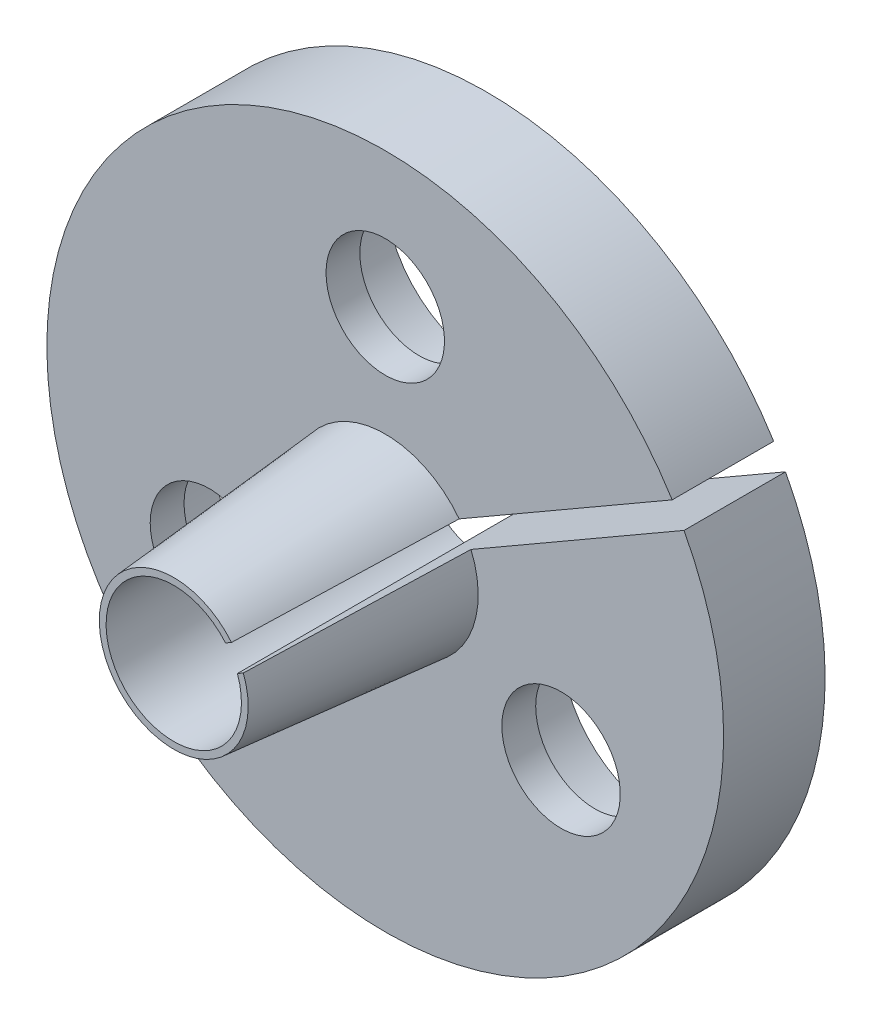
from build123d import *

# Parameters (mm, degrees)
SKETCH4_R           = 10
SKETCH4_R_2         = 2
BOSS_EXTRUDE4_DEPTH = 3
SKETCH5_R           = 1.75
CUT_EXTRUDE1_DEPTH  = 10.25
SKETCH7_R           = 3
CUT_EXTRUDE3_DEPTH  = 2
CUT_EXTRUDE2_DEPTH  = 10.25


with BuildPart() as part:
    # Sketch3 → Revolve1 (revolve)
    with BuildSketch(Plane(origin=(0, 0, 0), x_dir=(0, 0, -1), z_dir=(1, 0, 0))):
        Polygon((0, 2), (0, 2.746804147), (-6.25, 2.2), (-6.25, 2), align=None)
    revolve(axis=Axis((0, 0, 0), (0, 0, 1)))

    # Sketch4 → Boss-Extrude4 (add)
    with BuildSketch(Plane(origin=(0, 0, 0), x_dir=(-1, 0, 0), z_dir=(0, 0, -1))):
        Circle(SKETCH4_R)
        Circle(SKETCH4_R_2, mode=Mode.SUBTRACT)
    extrude(amount=BOSS_EXTRUDE4_DEPTH)

    # Sketch5 → Cut-Extrude1 (cut, through all)
    with BuildSketch(Plane(origin=(0, 0, -3), x_dir=(-1, 0, 0), z_dir=(0, 0, -1))):
        with Locations((0, 6)):
            Circle(SKETCH5_R)
        with Locations((-5.196152423, -3)):
            Circle(SKETCH5_R)
        with Locations((5.196152423, -3)):
            Circle(SKETCH5_R)
    extrude(amount=-CUT_EXTRUDE1_DEPTH, mode=Mode.SUBTRACT)

    # Sketch7 → Cut-Extrude3 (cut)
    with BuildSketch(Plane(origin=(0, 0, -3), x_dir=(-1, 0, 0), z_dir=(0, 0, -1))):
        with Locations((0, 6)):
            Circle(SKETCH7_R)
        with Locations((5.196152423, -3)):
            Circle(SKETCH7_R)
        with Locations((-5.196152423, -3)):
            Circle(SKETCH7_R)
    extrude(amount=-CUT_EXTRUDE3_DEPTH, mode=Mode.SUBTRACT)

    # Sketch6 → Cut-Extrude2 (cut, through all)
    with BuildSketch(Plane(origin=(0, 0, -3), x_dir=(-1, 0, 0), z_dir=(0, 0, -1))):
        with BuildLine():
            Line((-8.829948007, 4.69382767), (-0.175, -0.303108891))
            Line((-0.175, -0.303108891), (0, 0))
            Line((0, 0), (0.175, 0.303108891))
            Line((0.175, 0.303108891), (-8.479948007, 5.300045453))
            ThreePointArc((-8.479948007, 5.300045453), (-8.660254038, 5), (-8.829948007, 4.69382767))
        make_face()
    extrude(amount=-CUT_EXTRUDE2_DEPTH, mode=Mode.SUBTRACT)


solid = part.part
